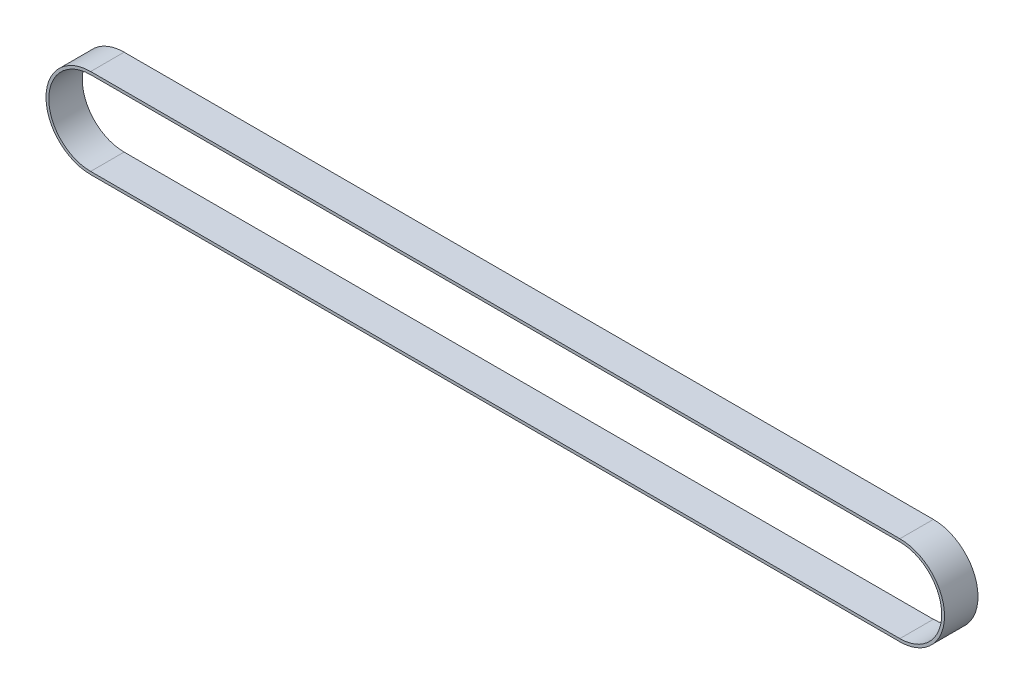
from build123d import *

# Parameters (mm, degrees)
EXTRUDE_THIN1_START = -0.5
EXTRUDE_THIN1_DEPTH = 6


with BuildPart() as part:
    # Sketch2 → Extrude-Thin1 (new body)
    with BuildSketch(Plane.XY.offset(EXTRUDE_THIN1_START)):
        with BuildLine():
            Line((145, -8.5), (0, -8.5))
            ThreePointArc((0, -8.5), (-8, -0.5), (0, 7.5))
            Line((0, 7.5), (145, 7.5))
            ThreePointArc((145, 7.5), (153, -0.5), (145, -8.5))
        make_face()
        with BuildLine():
            Line((145, -8), (0, -8))
            ThreePointArc((0, -8), (-7.5, -0.5), (0, 7))
            Line((0, 7), (145, 7))
            ThreePointArc((145, 7), (152.5, -0.5), (145, -8))
        make_face(mode=Mode.SUBTRACT)
    extrude(amount=-EXTRUDE_THIN1_DEPTH)


solid = part.part
